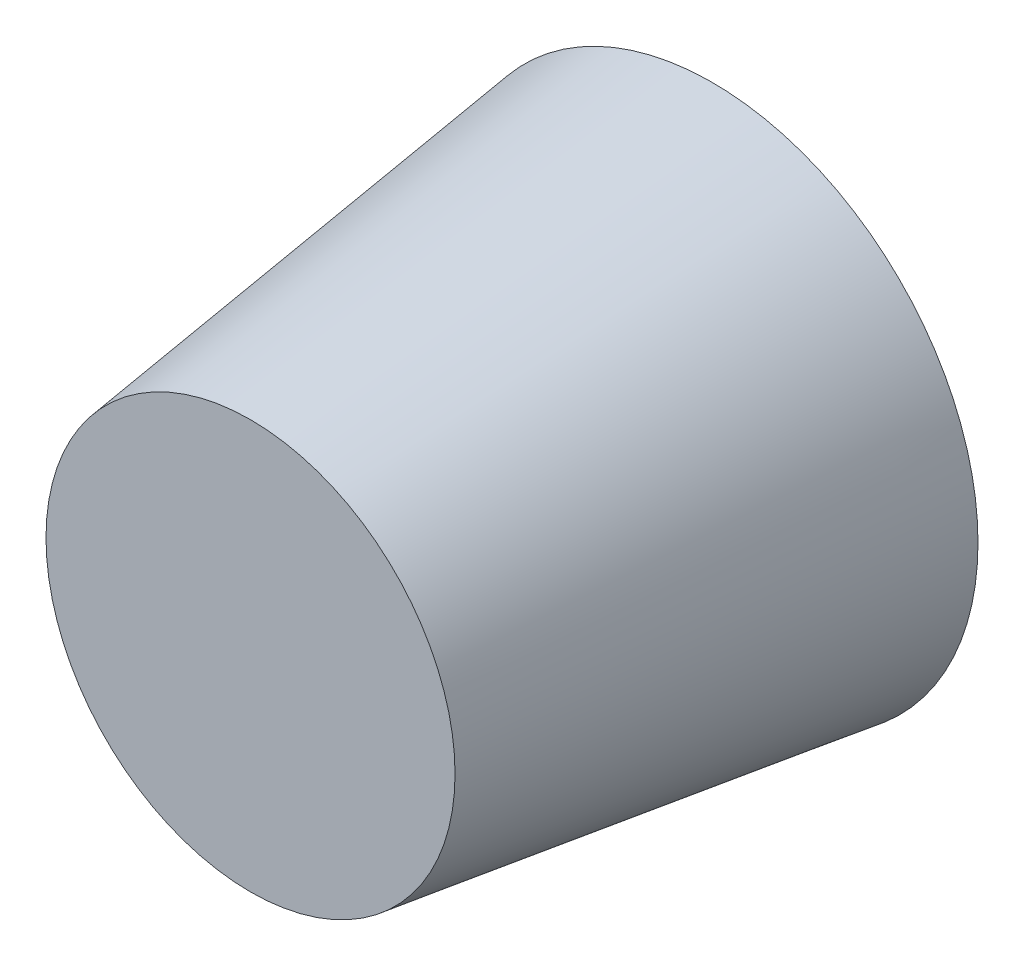
from build123d import *


with BuildPart() as part:
    # 草图4 → 旋转1 (revolve)
    with BuildSketch(Plane(origin=(0, 0, 0), x_dir=(1, 0, 0), z_dir=(0, 1, 0))):
        Polygon((0, 0), (0, 1), (14.5, 1), (19, 35), (20.132352941, 35), (15.5, 0), align=None)
    revolve(axis=Axis((0, 0, 0), (0, 0, -1)))


solid = part.part
